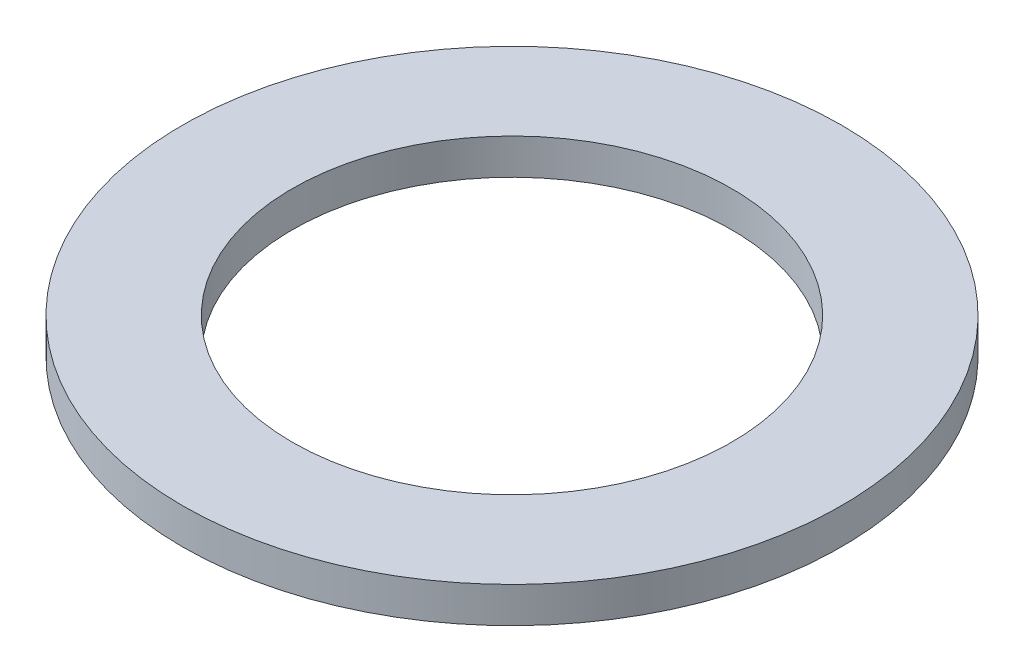
from build123d import *

# Parameters (mm, degrees)
SKETCH1_R           = 12
SKETCH1_R_2         = 8
BOSS_EXTRUDE1_DEPTH = 1.3


with BuildPart() as part:
    # Sketch1 → Boss-Extrude1 (new body)
    with BuildSketch(Plane(origin=(0, 0, 0), x_dir=(1, 0, 0), z_dir=(0, 1, 0))):
        Circle(SKETCH1_R)
        Circle(SKETCH1_R_2, mode=Mode.SUBTRACT)
    extrude(amount=BOSS_EXTRUDE1_DEPTH)


solid = part.part
